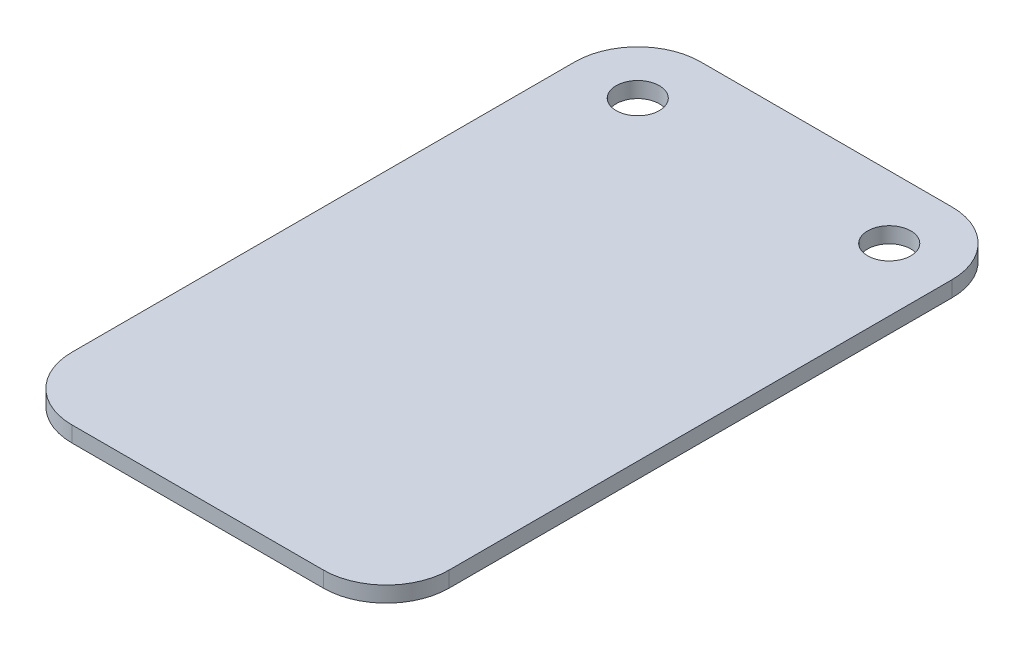
from build123d import *

# Parameters (mm, degrees)
SKETCH1_R           = 2.1828125
BOSS_EXTRUDE1_DEPTH = 1.5875


with BuildPart() as part:
    # Sketch1 → Boss-Extrude1 (new body)
    with BuildSketch(Plane(origin=(0, 0, 0), x_dir=(1, 0, 0), z_dir=(0, 1, 0))):
        with BuildLine():
            Line((6.35, 0), (31.75, 0))
            ThreePointArc((31.75, 0), (36.240128061, 1.859871939), (38.1, 6.35))
            Line((38.1, 6.35), (38.1, 57.15))
            ThreePointArc((38.1, 57.15), (36.240128061, 61.640128061), (31.75, 63.5))
            Line((31.75, 63.5), (6.35, 63.5))
            ThreePointArc((6.35, 63.5), (1.859871939, 61.640128061), (0, 57.15))
            Line((0, 57.15), (0, 6.35))
            ThreePointArc((0, 6.35), (1.859871939, 1.859871939), (6.35, 0))
        make_face()
        with Locations((31.75, 57.15)):
            Circle(SKETCH1_R, mode=Mode.SUBTRACT)
        with Locations((6.35, 57.15)):
            Circle(SKETCH1_R, mode=Mode.SUBTRACT)
    extrude(amount=BOSS_EXTRUDE1_DEPTH)


solid = part.part
